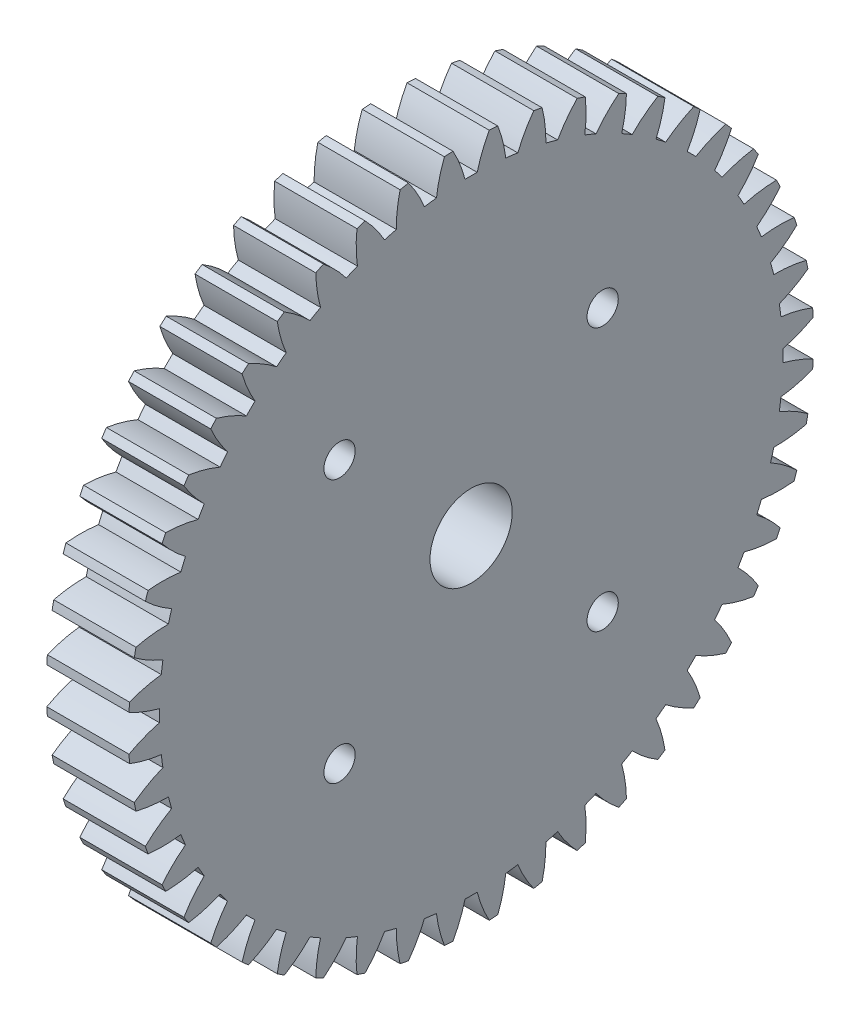
from build123d import *

# Parameters (mm, degrees)
BASPROSKE_W        = 12.7
BASPROSKE_H        = 52.916666667
TOOTHCUT_DEPTH     = 76.905449226
TEETHCUTS_COUNT    = 48
TEETHCUTS_ANGLE    = 352.5
BORSKE_R           = 6.35
BORE_DEPTH         = 50.8000508
SKETCH2_R          = 2.413
CUT_EXTRUDE1_DEPTH = 12.7


with BuildPart() as part:
    # BasProSke → Base-Revolve (revolve)
    with BuildSketch(Plane(origin=(0, 0, 0), x_dir=(1, 0, 0), z_dir=(0, 1, 0)), mode=Mode.PRIVATE) as base_revolve_sk:
        with Locations((6.35, 26.458333334)):
            Rectangle(BASPROSKE_W, BASPROSKE_H)
    revolve(base_revolve_sk.sketch.rotate(Axis((-10, 0, 0), (1, 0, 0)), 180), axis=Axis((-10, 0, 0), (1, 0, 0)))

    # TooCutSke → ToothCut (cut, through all)
    with BuildSketch(Plane(origin=(0, 0, 0), x_dir=(0, 0, -1), z_dir=(1, 0, 0))):
        with BuildLine():
            ThreePointArc((0.938681533, 48.143746576), (0, 48.152896667), (-0.938681533, 48.143746576))
            ThreePointArc((-0.938681533, 48.143746576), (-1.729356878, 50.56436869), (-2.816577529, 52.86709103))
            ThreePointArc((-2.816577529, 52.86709103), (0, 52.942066667), (2.816577529, 52.86709103))
            ThreePointArc((2.816577529, 52.86709103), (1.729356878, 50.56436869), (0.938681533, 48.143746576))
        make_face()
    toothcut = extrude(amount=TOOTHCUT_DEPTH, mode=Mode.SUBTRACT)

    # TeethCuts: ToothCut ×48 about axis
    teethcuts_axis = Axis((-10, 0, 0), (1, 0, 0))
    for i in range(1, TEETHCUTS_COUNT):
        add(toothcut.rotate(teethcuts_axis, i * TEETHCUTS_ANGLE / (TEETHCUTS_COUNT - 1)), mode=Mode.SUBTRACT)

    # BorSke → Bore (cut, symmetric)
    with BuildSketch(Plane(origin=(0, 0, 0), x_dir=(0, 0, -1), z_dir=(1, 0, 0))):
        with Locations(Location((0, 0, 0), (0, 0, 180))):
            Circle(BORSKE_R)
    extrude(amount=BORE_DEPTH, both=True, mode=Mode.SUBTRACT)

    # Sketch2 → Cut-Extrude1 (cut)
    with BuildSketch(Plane(origin=(12.7, 0, 0), x_dir=(0, 0, -1), z_dir=(1, 0, 0))):
        with Locations((-20.32, 20.32)):
            Circle(SKETCH2_R)
        with Locations((-20.32, -20.32)):
            Circle(SKETCH2_R)
        with Locations((20.32, -20.32)):
            Circle(SKETCH2_R)
        with Locations((20.32, 20.32)):
            Circle(SKETCH2_R)
    extrude(amount=-CUT_EXTRUDE1_DEPTH, mode=Mode.SUBTRACT)


solid = part.part
